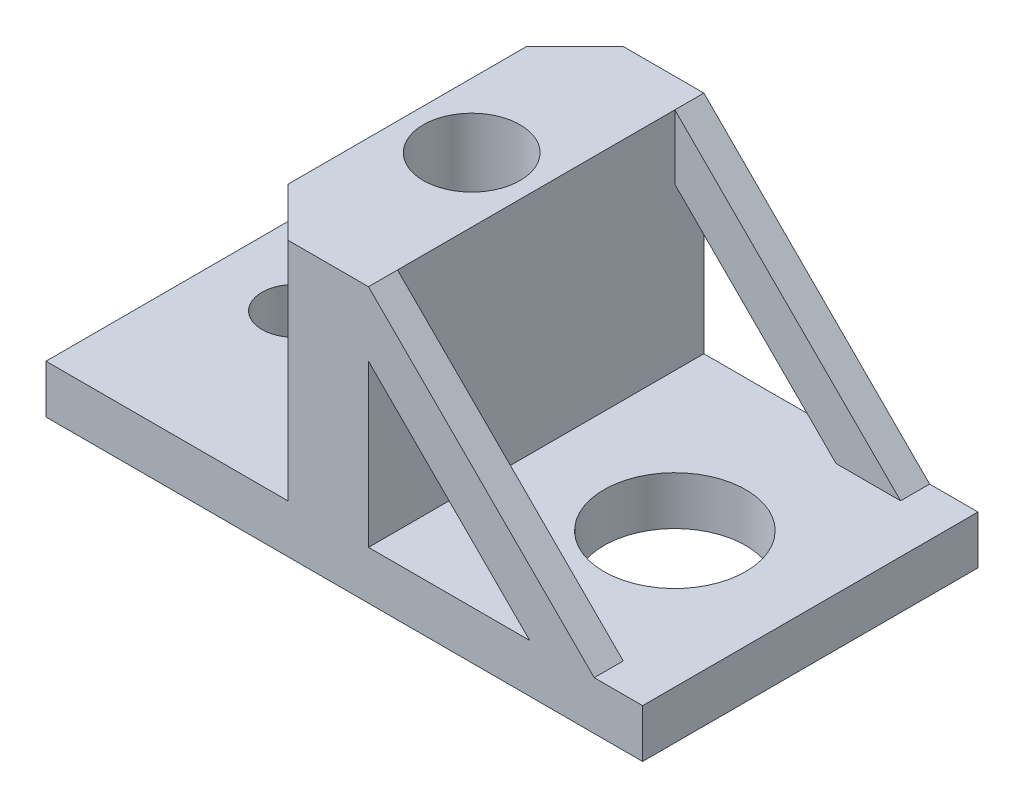
from build123d import *

# Parameters (mm, degrees)
SKETCH1_W           = 92.5
SKETCH1_H           = 52
SKETCH1_R           = 5.015
SKETCH1_R_2         = 7.5
SKETCH1_R_3         = 11
BOSS_EXTRUDE1_DEPTH = 7.5
SKETCH2_R           = 7.5
BOSS_EXTRUDE2_DEPTH = 35
BOSS_EXTRUDE3_DEPTH = 4.5
BOSS_EXTRUDE4_DEPTH = 4.5


with BuildPart() as part:
    # Sketch1 → Boss-Extrude1 (new body)
    with BuildSketch(Plane(origin=(0, 0, 0), x_dir=(1, 0, 0), z_dir=(0, 1, 0))):
        with Locations((46.25, 26)):
            Rectangle(SKETCH1_W, SKETCH1_H)
        with Locations((12.5, 26)):
            Circle(SKETCH1_R, mode=Mode.SUBTRACT)
        with Locations((40, 26)):
            Circle(SKETCH1_R_2, mode=Mode.SUBTRACT)
        with Locations((71.5, 26)):
            Circle(SKETCH1_R_3, mode=Mode.SUBTRACT)
    extrude(amount=BOSS_EXTRUDE1_DEPTH)

    # Sketch2 → Boss-Extrude2 (add)
    with BuildSketch(Plane(origin=(0, 7.5, 0), x_dir=(1, 0, 0), z_dir=(0, 1, 0))):
        Polygon((30, 7.5), (37.5, 0), (50, 0), (50, 52), (37.5, 52), (30, 44.5), align=None)
        with Locations((40, 26)):
            Circle(SKETCH2_R, mode=Mode.SUBTRACT)
    extrude(amount=BOSS_EXTRUDE2_DEPTH)

    # Sketch3 → Boss-Extrude3 (add)
    with BuildSketch(Plane.XY):
        Polygon((50, 42.5), (85, 7.5), (75, 7.5), (50, 32.5), align=None)
    extrude(amount=-BOSS_EXTRUDE3_DEPTH)

    # Sketch4 → Boss-Extrude4 (add)
    with BuildSketch(Plane(origin=(0, 0, -52), x_dir=(-1, 0, 0), z_dir=(0, 0, -1))):
        Polygon((-50, 42.5), (-85, 7.5), (-75, 7.5), (-50, 32.5), align=None)
    extrude(amount=-BOSS_EXTRUDE4_DEPTH)


solid = part.part
